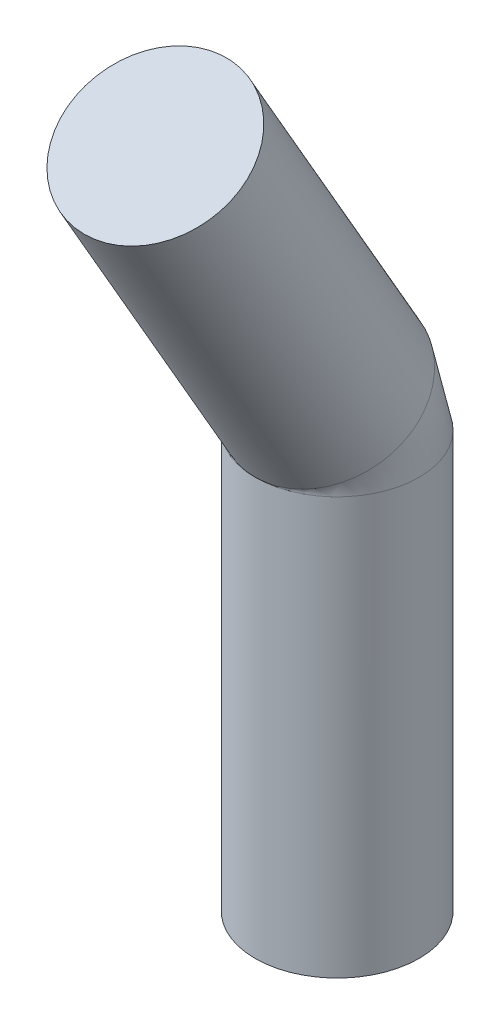
from build123d import *

# Parameters (mm, degrees)
SKETCH23_R          = 0.6
SKETCH25_R          = 0.6
BOSS_EXTRUDE2_DEPTH = 2.55


with BuildPart() as part:
    # Sweep4: sweep along a path in Sketch24
    with BuildLine(Plane(origin=(0, 0, 0), x_dir=(0, 0, -1), z_dir=(1, 0, 0))) as sweep4_path:
        Line((0, 0), (0, 0.5))
        ThreePointArc((0, 0.5), (-0.020444504, 0.655291427), (-0.080384758, 0.8))
        Line((-0.080384758, 0.8), (-1.330384758, 2.965063509))
    # Sketch23 → Sweep4 (sweep)
    with BuildSketch(Plane(origin=(0, 0, 0), x_dir=(1, 0, 0), z_dir=(0, 1, 0))):
        Circle(SKETCH23_R)
    sweep(path=sweep4_path.line)

    # Sketch25 → Boss-Extrude2 (add)
    with BuildSketch(Plane(origin=(0, 0, 0), x_dir=(-1, 0, 0), z_dir=(0, -1, 0))):
        Circle(SKETCH25_R)
    extrude(amount=BOSS_EXTRUDE2_DEPTH)


solid = part.part
